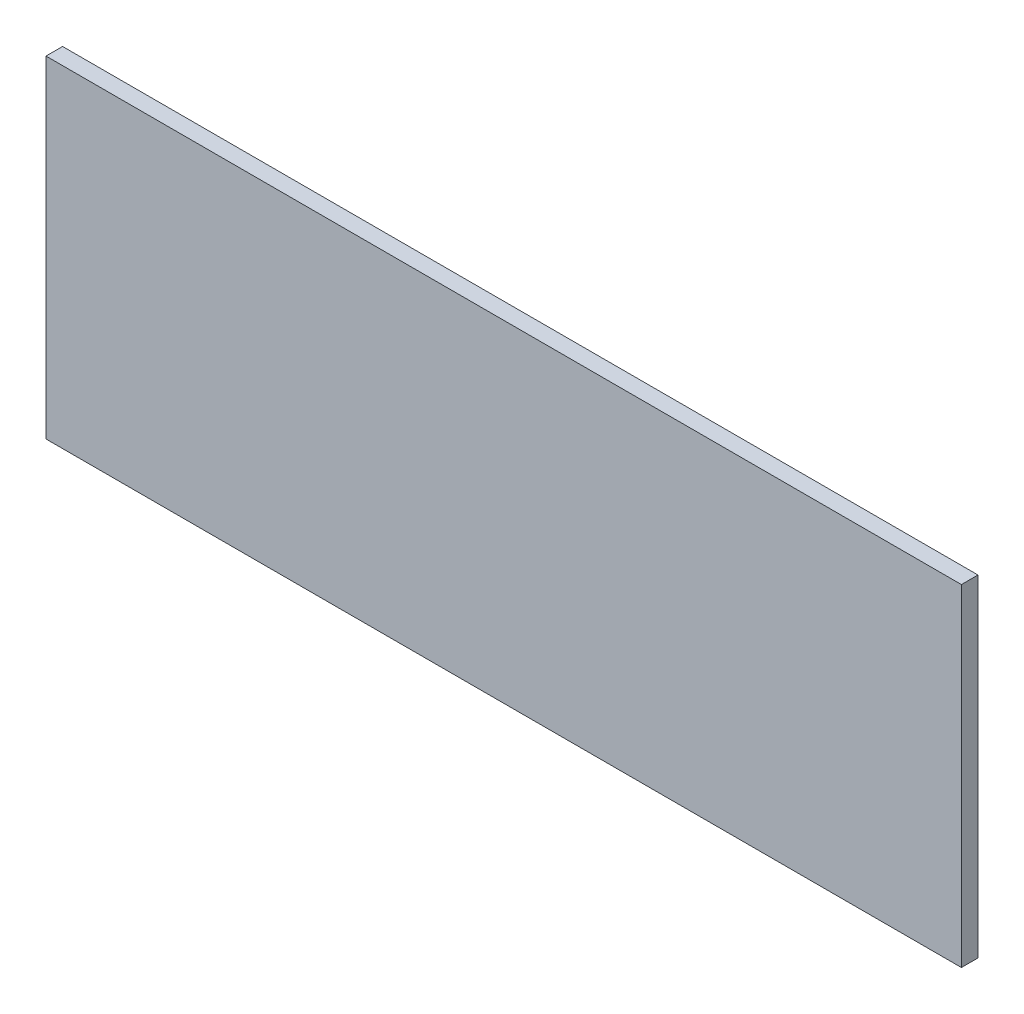
from build123d import *

# Parameters (mm, degrees)
SKETCH1_W           = 690
SKETCH1_H           = 250
BOSS_EXTRUDE1_DEPTH = 12.5


with BuildPart() as part:
    # Sketch1 → Boss-Extrude1 (new body)
    with BuildSketch(Plane.XY):
        Rectangle(SKETCH1_W, SKETCH1_H)
    extrude(amount=BOSS_EXTRUDE1_DEPTH)


solid = part.part
